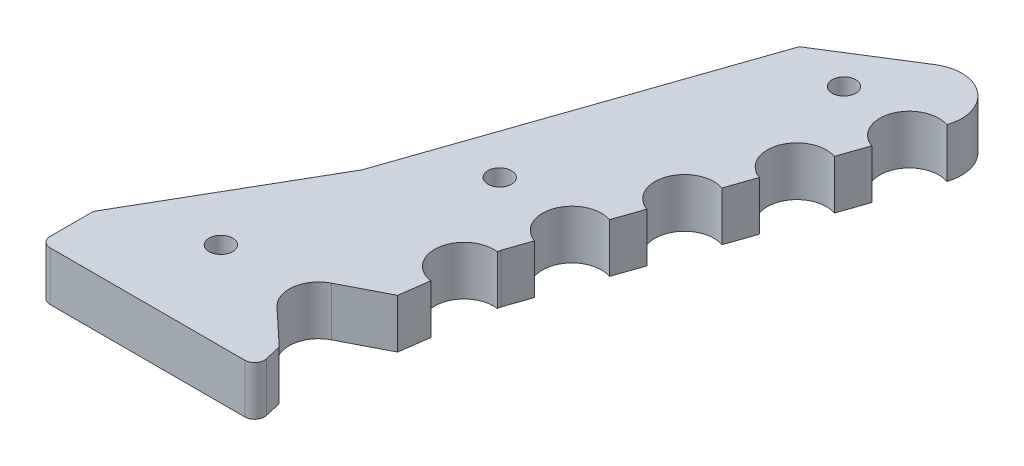
from build123d import *

# Parameters (mm, degrees)
BOSS_EXTRUDE1_DEPTH = 5
TEETH_CUTOUT_DEPTH  = 6
FILLET2_R           = 0.5
SKETCH3_R           = 1.2
HOLE_CUTOUT_DEPTH   = 6
CUT_EXTRUDE1_DEPTH  = 6
FILLET3_R           = 1


with BuildPart() as part:
    # Sketch1 → Boss-Extrude1 (new body)
    with BuildSketch(Plane(origin=(0, 0, 0), x_dir=(1, 0, 0), z_dir=(0, 1, 0))):
        with BuildLine():
            Line((0, 0), (0, 30))
            Line((0, 30), (10, 47.320508076))
            Line((10, 47.320508076), (21.394885406, 80.413658222))
            Line((21.394885406, 80.413658222), (29.86, 85.73736322))
            ThreePointArc((29.86, 85.73736322), (34.475009673, 85.485348682), (35.771556302, 81.049044765))
            Line((35.771556302, 81.049044765), (24.157889764, 47.320508076))
            Line((24.157889764, 47.320508076), (21.394885406, 27.512282337))
            Line((21.394885406, 27.512282337), (27.71, 0))
            Line((27.71, 0), (0, 0))
        make_face()
    extrude(amount=BOSS_EXTRUDE1_DEPTH)

    # Sketch2 → Teeth_Cutout (cut, through all)
    with BuildSketch(Plane(origin=(0, 5, 0), x_dir=(1, 0, 0), z_dir=(0, 1, 0))):
        with BuildLine():
            ThreePointArc((35.771556302, 81.049044765), (31.958296112, 79.189193501), (33.818147375, 75.375933311))
            Line((33.818147375, 75.375933311), (35.771556302, 81.049044765))
        make_face()
        with BuildLine():
            ThreePointArc((32.841442912, 72.539377584), (29.028182721, 70.679526321), (30.888033985, 66.866266131))
            Line((30.888033985, 66.866266131), (32.841442912, 72.539377584))
        make_face()
        with BuildLine():
            ThreePointArc((29.911329522, 64.029710404), (26.098069331, 62.16985914), (27.957920595, 58.35659895))
            Line((27.957920595, 58.35659895), (29.911329522, 64.029710404))
        make_face()
        with BuildLine():
            ThreePointArc((26.981216131, 55.520043223), (23.167955941, 53.66019196), (25.027807205, 49.84693177))
            Line((25.027807205, 49.84693177), (26.981216131, 55.520043223))
        make_face()
        with BuildLine():
            ThreePointArc((24.111726827, 46.989561847), (20.726042313, 44.43277864), (23.28282552, 41.047094125))
            Line((23.28282552, 41.047094125), (24.111726827, 46.989561847))
        make_face()
        with BuildLine():
            Line((17.745535287, 30.930212077), (21.394885406, 27.512282337))
            Line((21.394885406, 27.512282337), (22.868374866, 38.075860265))
            Line((22.868374866, 38.075860265), (18.423003833, 35.787044768))
            ThreePointArc((18.423003833, 35.787044768), (16.82505927, 33.534272802), (17.745535287, 30.930212077))
        make_face()
        with BuildLine():
            Line((19.827305771, 16.086577823), (24.453138026, 14.188769628))
            Line((24.453138026, 14.188769628), (22.066045454, 24.588321976))
            Line((22.066045454, 24.588321976), (18.730897185, 20.863166138))
            ThreePointArc((18.730897185, 20.863166138), (18.042030328, 18.190917128), (19.827305771, 16.086577823))
        make_face()
        with BuildLine():
            Line((22.885558392, 2.763065114), (27.511390647, 0.865256919))
            Line((27.511390647, 0.865256919), (25.124298075, 11.264809267))
            Line((25.124298075, 11.264809267), (21.789149806, 7.539653429))
            ThreePointArc((21.789149806, 7.539653429), (21.100282948, 4.867404419), (22.885558392, 2.763065114))
        make_face()
    extrude(amount=-TEETH_CUTOUT_DEPTH, mode=Mode.SUBTRACT)

    # Fillet2
    fillet2_edges = [part.edges().sort_by_distance(p)[0] for p in [
        (27.71, 2.5, 0),
        (27.511390647, 2.5, -0.865256919),
    ]]
    fillet(fillet2_edges, radius=FILLET2_R)

    # Sketch3 → Hole_Cutout (cut, through all)
    with BuildSketch(Plane(origin=(0, 5, 0), x_dir=(1, 0, 0), z_dir=(0, 1, 0))):
        with Locations((11.72836197, 9.402231348)):
            Circle(SKETCH3_R)
        with Locations((9.432786312, 33.534272802)):
            Circle(SKETCH3_R)
        with Locations((17.675442081, 53.66019196)):
            Circle(SKETCH3_R)
        with Locations((27.173268391, 79.189193501)):
            Circle(SKETCH3_R)
    extrude(amount=-HOLE_CUTOUT_DEPTH, mode=Mode.SUBTRACT)

    # Sketch4 → Cut-Extrude1 (cut, through all)
    with BuildSketch(Plane(origin=(0, 5, 0), x_dir=(1, 0, 0), z_dir=(0, 1, 0))):
        Polygon((22.066045454, 24.588321976), (0, 24.588321976), (0, 0), (28.614713262, 0), (28.614713262, 24.588321976), align=None)
    extrude(amount=-CUT_EXTRUDE1_DEPTH, mode=Mode.SUBTRACT)

    # Fillet3
    fillet3_edges = [part.edges().sort_by_distance(p)[0] for p in [
        (0, 2.5, -24.588321976),
        (22.066045454, 2.5, -24.588321976),
    ]]
    fillet(fillet3_edges, radius=FILLET3_R)


solid = part.part
